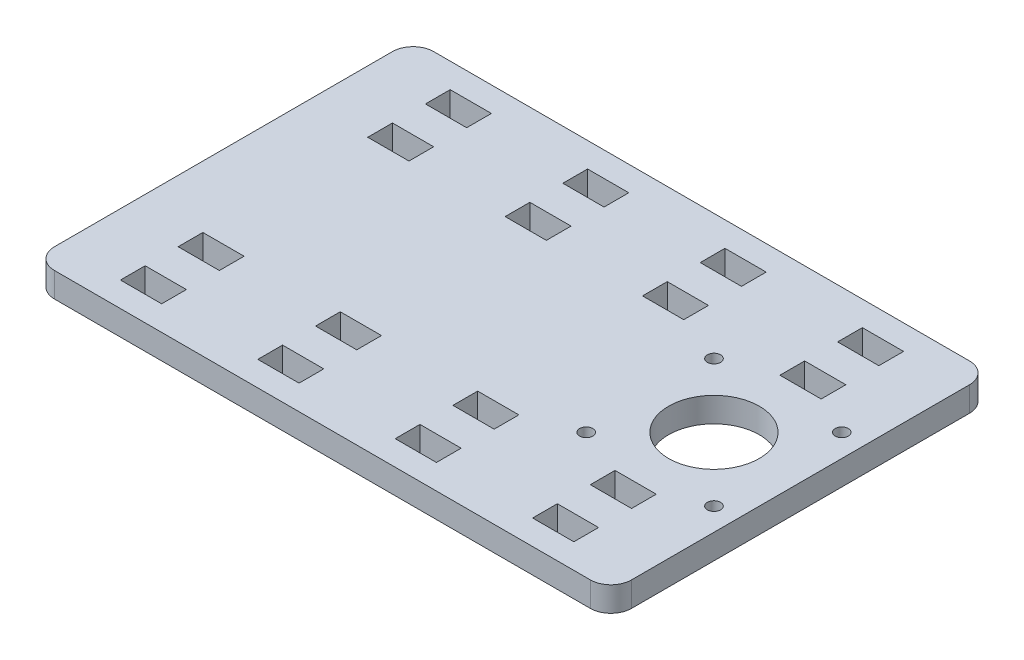
from build123d import *

# Parameters (mm, degrees)
SKETCH1_W            = 140
SKETCH1_H            = 92
BOSS_EXTRUDE1_DEPTH  = 6
SKETCH3_R            = 11
SKETCH3_R_2          = 1.6
CUT_EXTRUDE2_DEPTH   = 7
SKETCH6_W            = 10
SKETCH6_H            = 6
CUT_EXTRUDE12_DEPTH  = 4
SKETCH61_W           = 10
SKETCH61_H           = 6
CUT_EXTRUDE14_DEPTH  = 4
SKETCH62_W           = 10
SKETCH62_H           = 6
CUT_EXTRUDE15_DEPTH  = 4
SKETCH63_W           = 10
SKETCH63_H           = 6
CUT_EXTRUDE16_DEPTH  = 4
SKETCH65_W           = 10
SKETCH65_H           = 6
CUT_EXTRUDE17_DEPTH  = 4
SKETCH66_W           = 10
SKETCH66_H           = 6
CUT_EXTRUDE18_DEPTH  = 4
SKETCH67_W           = 10
SKETCH67_H           = 6
CUT_EXTRUDE19_DEPTH  = 4
SKETCH68_W           = 10
SKETCH68_H           = 6
CUT_EXTRUDE110_DEPTH = 4
FILLET1_R            = 5


with BuildPart() as part:
    # Sketch1 → Boss-Extrude1 (new body)
    with BuildSketch(Plane(origin=(0, 0, 0), x_dir=(1, 0, 0), z_dir=(0, 1, 0))):
        Rectangle(SKETCH1_W, SKETCH1_H)
    extrude(amount=BOSS_EXTRUDE1_DEPTH)

    # Sketch3 → Cut-Extrude2 (cut, through all)
    with BuildSketch(Plane(origin=(0, 6, 0), x_dir=(1, 0, 0), z_dir=(0, 1, 0))):
        with Locations((49, 0)):
            Circle(SKETCH3_R)
        with Locations((33.5, -15.5)):
            Circle(SKETCH3_R_2)
        with Locations((33.5, 15.5)):
            Circle(SKETCH3_R_2)
        with Locations((64.5, 15.5)):
            Circle(SKETCH3_R_2)
        with Locations((64.5, -15.5)):
            Circle(SKETCH3_R_2)
    extrude(amount=-CUT_EXTRUDE2_DEPTH, mode=Mode.SUBTRACT)

    # Sketch6 → Cut-Extrude12 (cut, symmetric)
    with BuildSketch(Plane(origin=(49.232221392, 3, -81), x_dir=(1, 0, 0), z_dir=(0, 1, 0))):
        with Locations((0.767778608, -44)):
            Rectangle(SKETCH6_W, SKETCH6_H)
    cut_extrude12 = extrude(amount=CUT_EXTRUDE12_DEPTH, both=True, mode=Mode.SUBTRACT)

    # Sketch61 → Cut-Extrude14 (cut, symmetric)
    with BuildSketch(Plane(origin=(15.898888059, 3, -81), x_dir=(1, 0, 0), z_dir=(0, 1, 0))):
        with Locations((0.767778608, -44)):
            Rectangle(SKETCH61_W, SKETCH61_H)
    cut_extrude14 = extrude(amount=CUT_EXTRUDE14_DEPTH, both=True, mode=Mode.SUBTRACT)

    # Sketch62 → Cut-Extrude15 (cut, symmetric)
    with BuildSketch(Plane(origin=(-17.434445274, 3, -81), x_dir=(1, 0, 0), z_dir=(0, 1, 0))):
        with Locations((0.767778608, -44)):
            Rectangle(SKETCH62_W, SKETCH62_H)
    cut_extrude15 = extrude(amount=CUT_EXTRUDE15_DEPTH, both=True, mode=Mode.SUBTRACT)

    # Sketch63 → Cut-Extrude16 (cut, symmetric)
    with BuildSketch(Plane(origin=(-50.767778608, 3, -81), x_dir=(1, 0, 0), z_dir=(0, 1, 0))):
        with Locations((0.767778608, -44)):
            Rectangle(SKETCH63_W, SKETCH63_H)
    cut_extrude16 = extrude(amount=CUT_EXTRUDE16_DEPTH, both=True, mode=Mode.SUBTRACT)

    # Sketch65 → Cut-Extrude17 (cut, symmetric)
    with BuildSketch(Plane(origin=(49.232221392, 3, -67), x_dir=(1, 0, 0), z_dir=(0, 1, 0))):
        with Locations((0.767778608, -44)):
            Rectangle(SKETCH65_W, SKETCH65_H)
    cut_extrude17 = extrude(amount=CUT_EXTRUDE17_DEPTH, both=True, mode=Mode.SUBTRACT)

    # Sketch66 → Cut-Extrude18 (cut, symmetric)
    with BuildSketch(Plane(origin=(15.898888059, 3, -67), x_dir=(1, 0, 0), z_dir=(0, 1, 0))):
        with Locations((0.767778608, -44)):
            Rectangle(SKETCH66_W, SKETCH66_H)
    cut_extrude18 = extrude(amount=CUT_EXTRUDE18_DEPTH, both=True, mode=Mode.SUBTRACT)

    # Sketch67 → Cut-Extrude19 (cut, symmetric)
    with BuildSketch(Plane(origin=(-17.434445274, 3, -67), x_dir=(1, 0, 0), z_dir=(0, 1, 0))):
        with Locations((0.767778608, -44)):
            Rectangle(SKETCH67_W, SKETCH67_H)
    cut_extrude19 = extrude(amount=CUT_EXTRUDE19_DEPTH, both=True, mode=Mode.SUBTRACT)

    # Sketch68 → Cut-Extrude110 (cut, symmetric)
    with BuildSketch(Plane(origin=(-50.767778608, 3, -67), x_dir=(1, 0, 0), z_dir=(0, 1, 0))):
        with Locations((0.767778608, -44)):
            Rectangle(SKETCH68_W, SKETCH68_H)
    cut_extrude110 = extrude(amount=CUT_EXTRUDE110_DEPTH, both=True, mode=Mode.SUBTRACT)

    # Mirror1: Cut-Extrude12, Cut-Extrude14, Cut-Extrude15, Cut-Extrude16, Cut-Extrude17, Cut-Extrude18, Cut-Extrude19, Cut-Extrude110 across plane
    add(cut_extrude12.mirror(Plane.XY), mode=Mode.SUBTRACT)
    add(cut_extrude14.mirror(Plane.XY), mode=Mode.SUBTRACT)
    add(cut_extrude15.mirror(Plane.XY), mode=Mode.SUBTRACT)
    add(cut_extrude16.mirror(Plane.XY), mode=Mode.SUBTRACT)
    add(cut_extrude17.mirror(Plane.XY), mode=Mode.SUBTRACT)
    add(cut_extrude18.mirror(Plane.XY), mode=Mode.SUBTRACT)
    add(cut_extrude19.mirror(Plane.XY), mode=Mode.SUBTRACT)
    add(cut_extrude110.mirror(Plane.XY), mode=Mode.SUBTRACT)

    # Fillet1
    fillet1_edges = [part.edges().sort_by_distance(p)[0] for p in [
        (70, 3, 46),
        (-70, 3, 46),
        (-70, 3, -46),
        (70, 3, -46),
    ]]
    fillet(fillet1_edges, radius=FILLET1_R)


solid = part.part
